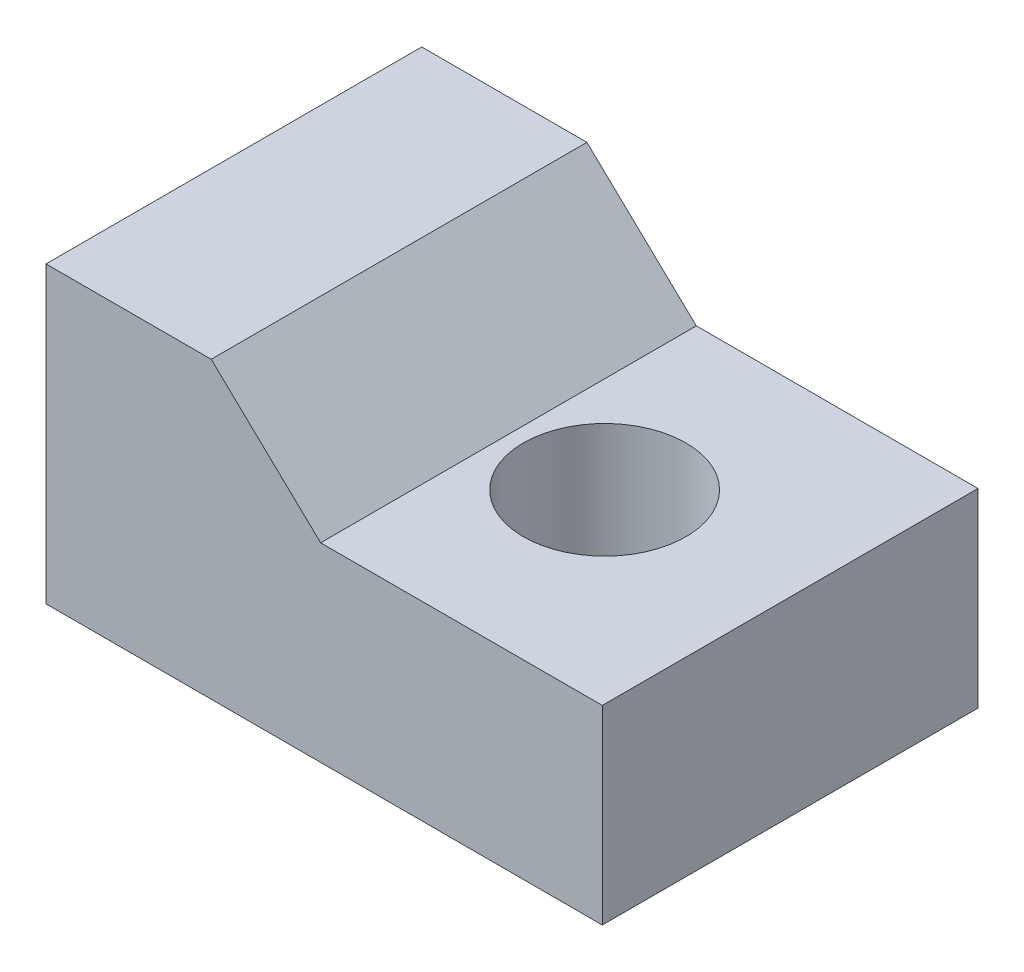
from build123d import *

# Parameters (mm, degrees)
BOSS_EXTRUDE1_DEPTH = 18.3134
SKETCH2_R           = 3.9624
CUT_EXTRUDE1_DEPTH  = 10.271
SKETCH3_R           = 3.81
CUT_EXTRUDE2_DEPTH  = 6.35


with BuildPart() as part:
    # Sketch1 → Boss-Extrude1 (new body)
    with BuildSketch(Plane.XY):
        Polygon((0, 0), (0, 14.351), (8.0518, 14.351), (13.3858, 9.271), (27.1145, 9.271), (27.1145, 0), align=None)
    extrude(amount=BOSS_EXTRUDE1_DEPTH)

    # Sketch2 → Cut-Extrude1 (cut, through all)
    with BuildSketch(Plane(origin=(0, 9.271, 0), x_dir=(1, 0, 0), z_dir=(0, 1, 0))):
        with Locations(Location((18.0721, -9.1567, 0), (0, 0, 180))):  # turned: the seam where the file's is
            Circle(SKETCH2_R)
    extrude(amount=-CUT_EXTRUDE1_DEPTH, mode=Mode.SUBTRACT)

    # Sketch3 → Cut-Extrude2 (cut)
    with BuildSketch(Plane.ZY):
        with Locations((9.1567, 6.096)):
            Circle(SKETCH3_R)
    extrude(amount=-CUT_EXTRUDE2_DEPTH, mode=Mode.SUBTRACT)


solid = part.part
